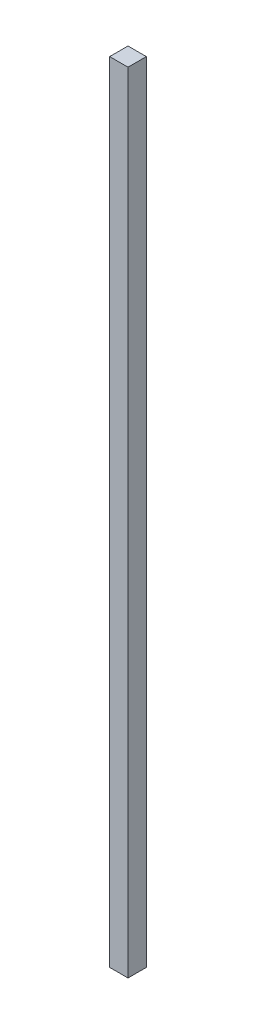
from build123d import *

# Parameters (mm, degrees)
SKETCH1_W           = 20
SKETCH1_H           = 20
BOSS_EXTRUDE1_DEPTH = 860


with BuildPart() as part:
    # Sketch1 → Boss-Extrude1 (new body)
    with BuildSketch(Plane(origin=(0, 0, 0), x_dir=(1, 0, 0), z_dir=(0, 1, 0))):
        with Locations((10, -10)):
            Rectangle(SKETCH1_W, SKETCH1_H)
    extrude(amount=BOSS_EXTRUDE1_DEPTH)


solid = part.part
